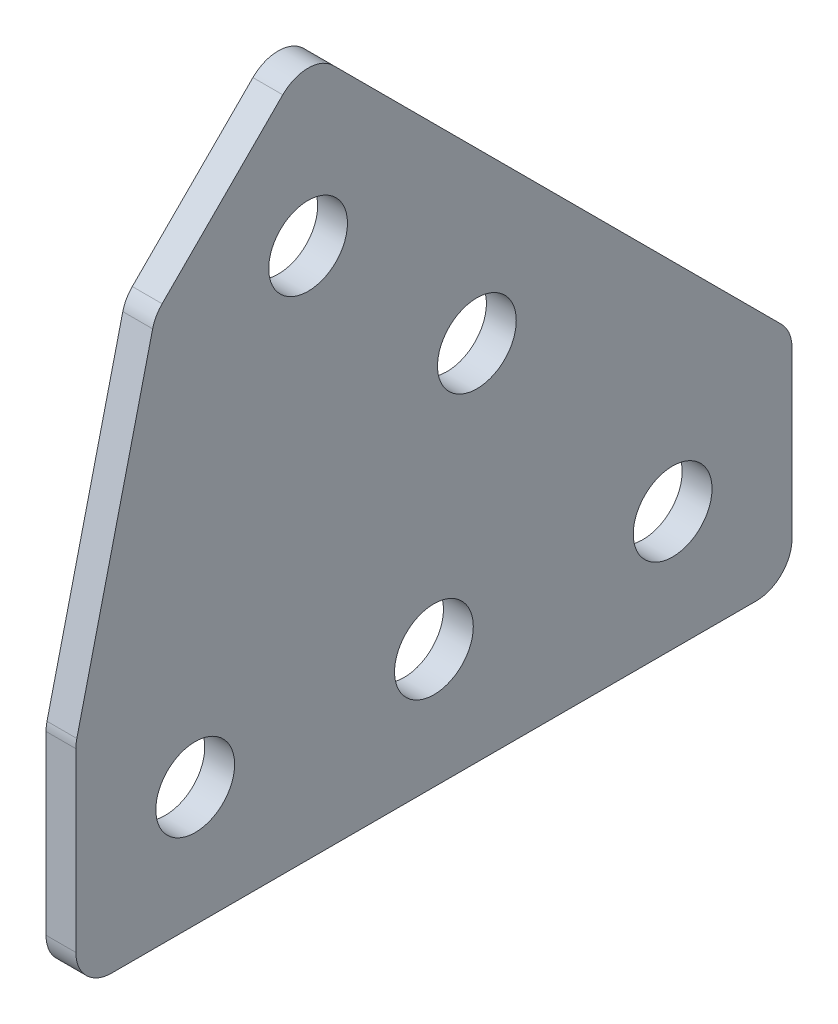
from build123d import *

# Parameters (mm, degrees)
BOSS_EXTRUDE1_DEPTH = 2.5
SKETCH2_R           = 3.3
CUT_EXTRUDE1_DEPTH  = 98.753931239
LPATTERN1_COUNT     = 3
LPATTERN1_PITCH     = 20
SKETCH2_4_R         = 3.3
CUT_EXTRUDE2_DEPTH  = 98.753931239
LPATTERN2_COUNT     = 2
LPATTERN2_PITCH     = 20
FILLET1_R           = 3


with BuildPart() as part:
    # Sketch1 → Boss-Extrude1 (new body)
    with BuildSketch(Plane(origin=(0, 0, 0), x_dir=(0, 0, -1), z_dir=(1, 0, 0))):
        Polygon((-78.140120378, 0), (-18.140120378, 0), (-18.140120378, 18.140120378), (-58.68306962, 58.68306962), (-71.510071751, 45.856067489), (-78.140120378, 18.140120378), align=None)
    extrude(amount=BOSS_EXTRUDE1_DEPTH)

    # Sketch2 → Cut-Extrude1 (cut, through all)
    with BuildSketch(Plane(origin=(2.5, 0, 0), x_dir=(0, 0, -1), z_dir=(1, 0, 0))):
        with Locations((-28.140120378, 10)):
            Circle(SKETCH2_R)
    cut_extrude1 = extrude(amount=-CUT_EXTRUDE1_DEPTH, mode=Mode.SUBTRACT)

    # LPattern1: Cut-Extrude1 ×3
    with Locations(*[(0, 0, i * LPATTERN1_PITCH) for i in range(1, LPATTERN1_COUNT)]):
        add(cut_extrude1, mode=Mode.SUBTRACT)

    # Sketch2_4 → Cut-Extrude2 (cut, through all)
    with BuildSketch(Plane(origin=(2.5, 0, 0), x_dir=(0, 0, -1), z_dir=(1, 0, 0))):
        with Locations((-58.68306962, 44.540933996)):
            Circle(SKETCH2_4_R)
    cut_extrude2 = extrude(amount=-CUT_EXTRUDE2_DEPTH, mode=Mode.SUBTRACT)

    # LPattern2: Cut-Extrude2 ×2
    with Locations(*[Vector(0, -0.7071067811865476, -0.7071067811865476) * (i * LPATTERN2_PITCH) for i in range(1, LPATTERN2_COUNT)]):
        add(cut_extrude2, mode=Mode.SUBTRACT)

    # Fillet1
    fillet1_edges = [part.edges().sort_by_distance(p)[0] for p in [
        (1.25, 0, 18.140120378),
        (1.25, 18.140120378, 18.140120378),
        (1.25, 58.68306962, 58.68306962),
        (1.25, 0, 78.140120378),
        (1.25, 18.140120378, 78.140120378),
        (1.25, 45.856067489, 71.510071751),
    ]]
    fillet(fillet1_edges, radius=FILLET1_R)


solid = part.part
